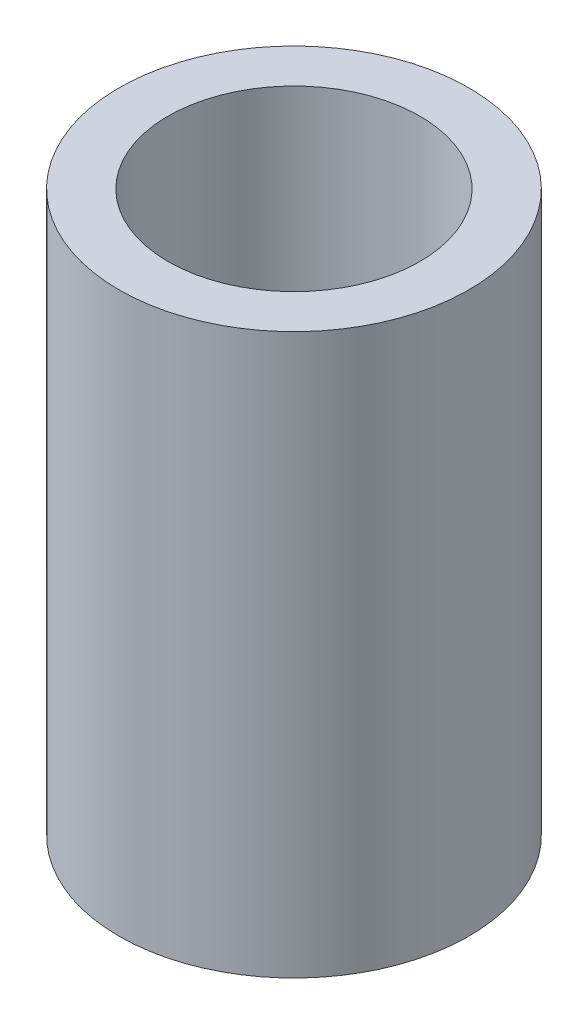
from build123d import *

# Parameters (mm, degrees)
SKETCH1_R           = 2.5
SKETCH1_R_2         = 1.8
BOSS_EXTRUDE1_DEPTH = 8


with BuildPart() as part:
    # Sketch1 → Boss-Extrude1 (new body)
    with BuildSketch(Plane(origin=(0, 0, 0), x_dir=(1, 0, 0), z_dir=(0, 1, 0))):
        with Locations((-9.865341469, -1.740295336)):
            Circle(SKETCH1_R)
        with Locations((-9.865341469, -1.740295336)):
            Circle(SKETCH1_R_2, mode=Mode.SUBTRACT)
    extrude(amount=BOSS_EXTRUDE1_DEPTH)


solid = part.part
